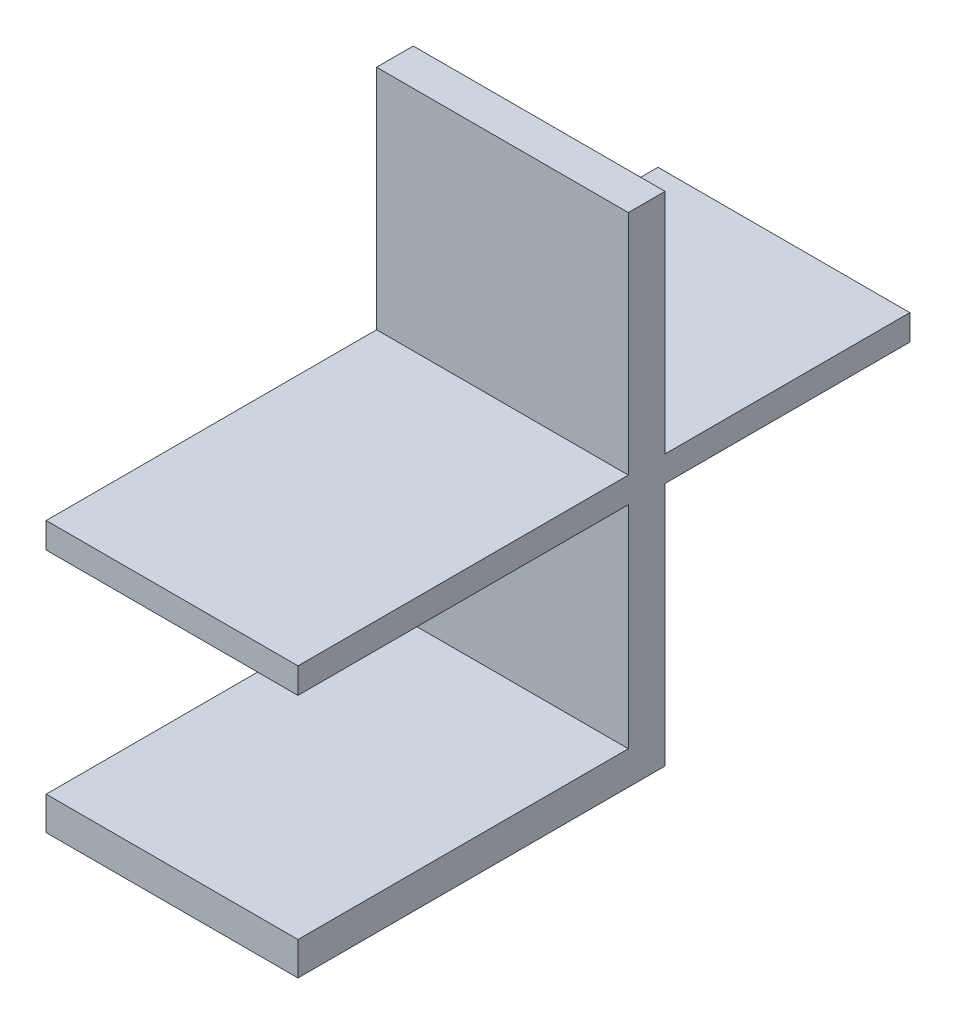
from build123d import *

# Parameters (mm, degrees)
SKETCH1_W                = 20.576303651
SKETCH1_H                = 2.09043177
BOSS_EXTRUDE1_DEPTH      = 30
BOSS_EXTRUDE1_DEPTH_BACK = 20
SKETCH2_W                = 20.576303651
SKETCH2_H                = 18.581877963
BOSS_EXTRUDE2_DEPTH      = 3
SKETCH3_W                = 20.576303651
SKETCH3_H                = 3
BOSS_EXTRUDE3_DEPTH      = 20
SKETCH4_W                = 20.576303651
SKETCH4_H                = 2.723460459
BOSS_EXTRUDE4_DEPTH      = 27


with BuildPart() as part:
    # Sketch1 → Boss-Extrude1 (new body, two sides)
    with BuildSketch(Plane.XY.offset(195.567247699)) as boss_extrude1_sk:
        with Locations((100.659362947, 26.580882383)):
            Rectangle(SKETCH1_W, SKETCH1_H)
    extrude(amount=BOSS_EXTRUDE1_DEPTH)
    extrude(boss_extrude1_sk.sketch, amount=-BOSS_EXTRUDE1_DEPTH_BACK)

    # Sketch2 → Boss-Extrude2 (add)
    with BuildSketch(Plane.XY.offset(195.567247699)):
        with Locations((100.659362947, 36.91703725)):
            Rectangle(SKETCH2_W, SKETCH2_H)
    extrude(amount=BOSS_EXTRUDE2_DEPTH)

    # Sketch3 → Boss-Extrude3 (add)
    with BuildSketch(Plane.XZ.offset(-25.535666498)):
        with Locations((100.659362947, 197.067247699)):
            Rectangle(SKETCH3_W, SKETCH3_H)
    extrude(amount=BOSS_EXTRUDE3_DEPTH)

    # Sketch4 → Boss-Extrude4 (add)
    with BuildSketch(Plane.XY.offset(198.567247699)):
        with Locations((100.659362947, 6.897396728)):
            Rectangle(SKETCH4_W, SKETCH4_H)
    extrude(amount=BOSS_EXTRUDE4_DEPTH)


solid = part.part
